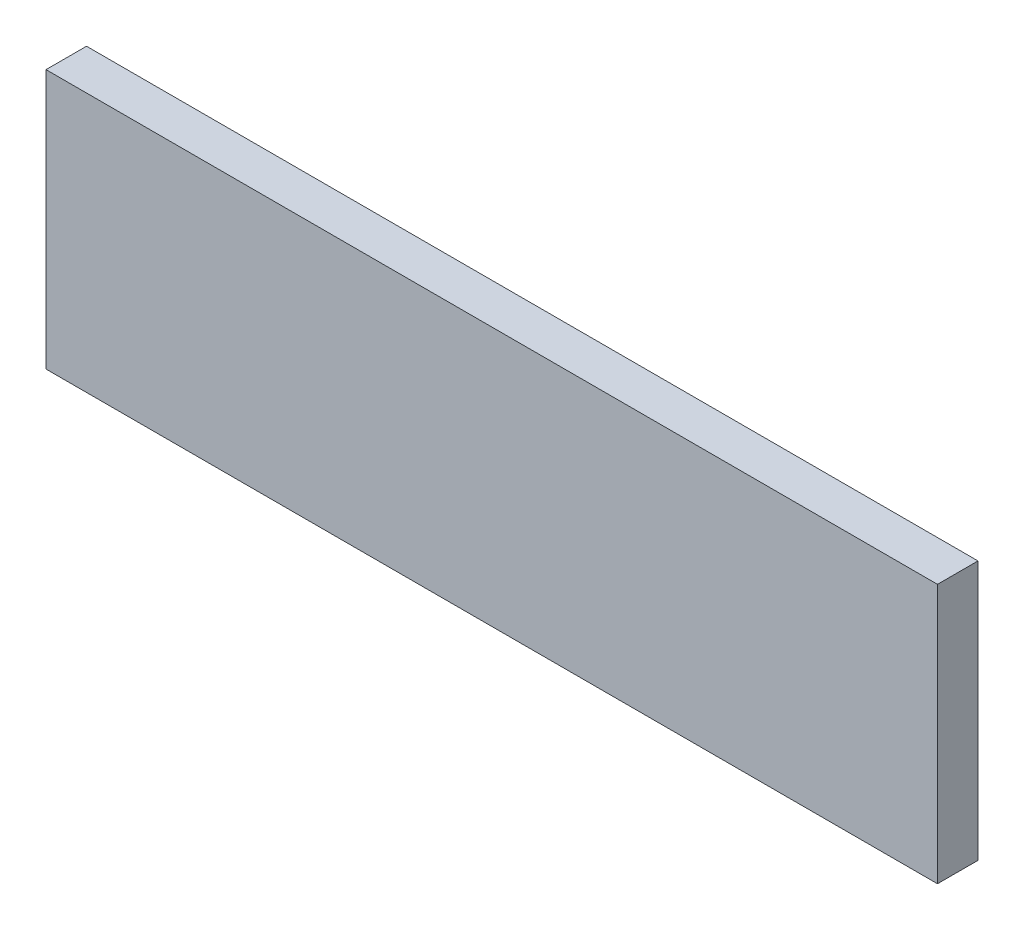
from build123d import *

# Parameters (mm, degrees)
SKETCH1_W           = 55
SKETCH1_H           = 16
BOSS_EXTRUDE1_DEPTH = 2.5


with BuildPart() as part:
    # Sketch1 → Boss-Extrude1 (new body)
    with BuildSketch(Plane.XY):
        Rectangle(SKETCH1_W, SKETCH1_H)
    extrude(amount=BOSS_EXTRUDE1_DEPTH)


solid = part.part
